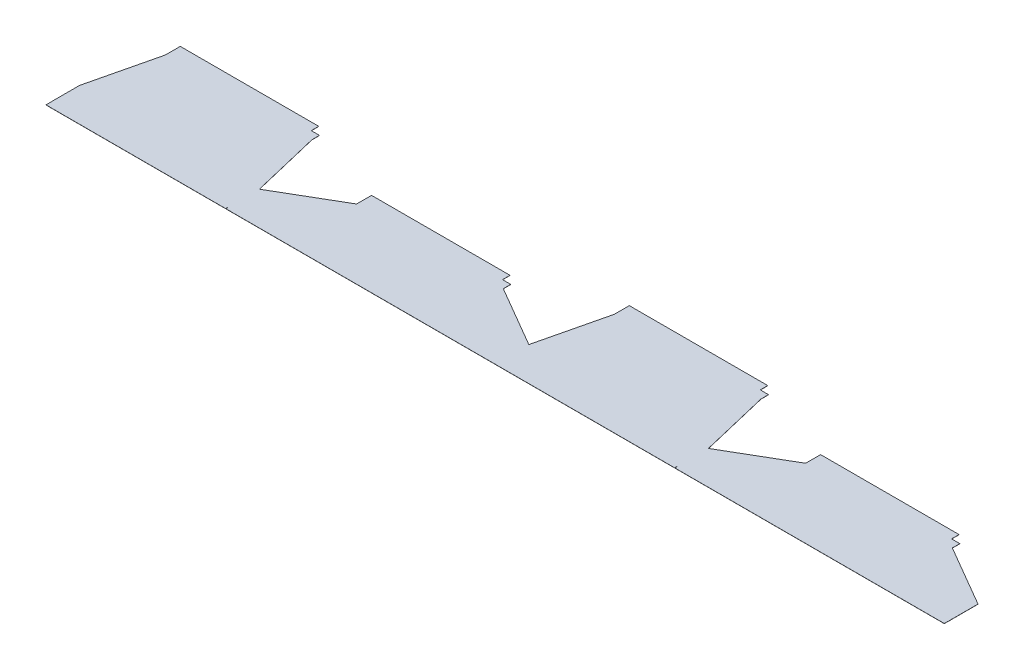
from build123d import *

# Parameters (mm, degrees)
BOSS_EXTRUDE1_DEPTH = 0.4572
BOSS_EXTRUDE2_DEPTH = 0.4572
LPATTERN1_COUNT     = 2
LPATTERN1_PITCH     = 1524


with BuildPart() as part:
    # Sketch1 → Boss-Extrude1 (new body)
    with BuildSketch(Plane(origin=(0, 0, 0), x_dir=(1, 0, 0), z_dir=(0, 1, 0))):
        Polygon((0, 0), (0, 12.7), (-0.254, 12.7), (-0.254, 114.3), (55.88, 348.97991828), (55.88, 399.77991828), (525.78, 399.77991828), (525.78, 374.37991828), (553.72, 374.37991828), (553.72, 348.97991828), (609.854, 114.3), (609.854, 12.7), (609.6, 12.7), (609.6, 0), align=None)
    boss_extrude1 = extrude(amount=BOSS_EXTRUDE1_DEPTH)

    # Sketch3 → Boss-Extrude2 (add)
    with BuildSketch(Plane(origin=(0, 0, 0), x_dir=(1, 0, 0), z_dir=(0, 1, 0))):
        Polygon((610.108, 0), (610.108, 12.7), (609.854, 12.7), (609.854, 114.3), (818.388, 235.705357559), (818.388, 286.505357559), (1288.288, 286.505357559), (1288.288, 261.105357559), (1316.228, 261.105357559), (1316.228, 235.705357559), (1524.762, 114.3), (1524.762, 12.7), (1524.508, 12.7), (1524.508, 0), align=None)
    boss_extrude2 = extrude(amount=BOSS_EXTRUDE2_DEPTH)

    # LPattern1: Boss-Extrude1, Boss-Extrude2 ×2
    with Locations(*[(i * LPATTERN1_PITCH, 0, 0) for i in range(1, LPATTERN1_COUNT)]):
        add(boss_extrude1)
        add(boss_extrude2)


solid = part.part
